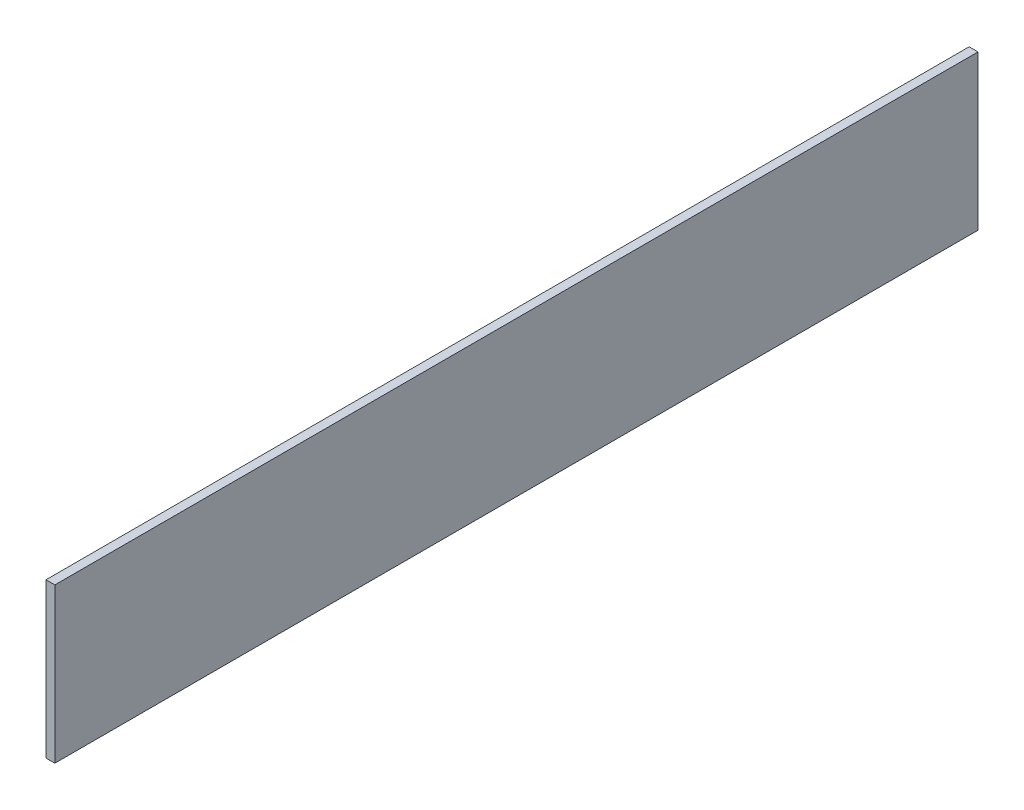
from build123d import *

# Parameters (mm, degrees)
SKETCH1_W           = 35
SKETCH1_H           = 200
BOSS_EXTRUDE1_DEPTH = 2.5
SKETCH2_W           = 260
SKETCH2_H           = 43.5
BOSS_EXTRUDE2_DEPTH = 2.5


with BuildPart() as part:
    # Sketch1 → Boss-Extrude1 (new body, symmetric)
    with BuildSketch(Plane.YZ):
        with Locations((-17.5, 0)):
            Rectangle(SKETCH1_W, SKETCH1_H)
    extrude(amount=BOSS_EXTRUDE1_DEPTH, both=True)

    # Sketch2 → Boss-Extrude2 (add)
    with BuildSketch(Plane(origin=(0, 0, 0), x_dir=(0, 0, -1), z_dir=(1, 0, 0))):
        with Locations((0, -19.25)):
            Rectangle(SKETCH2_W, SKETCH2_H)
    extrude(amount=BOSS_EXTRUDE2_DEPTH)


solid = part.part
